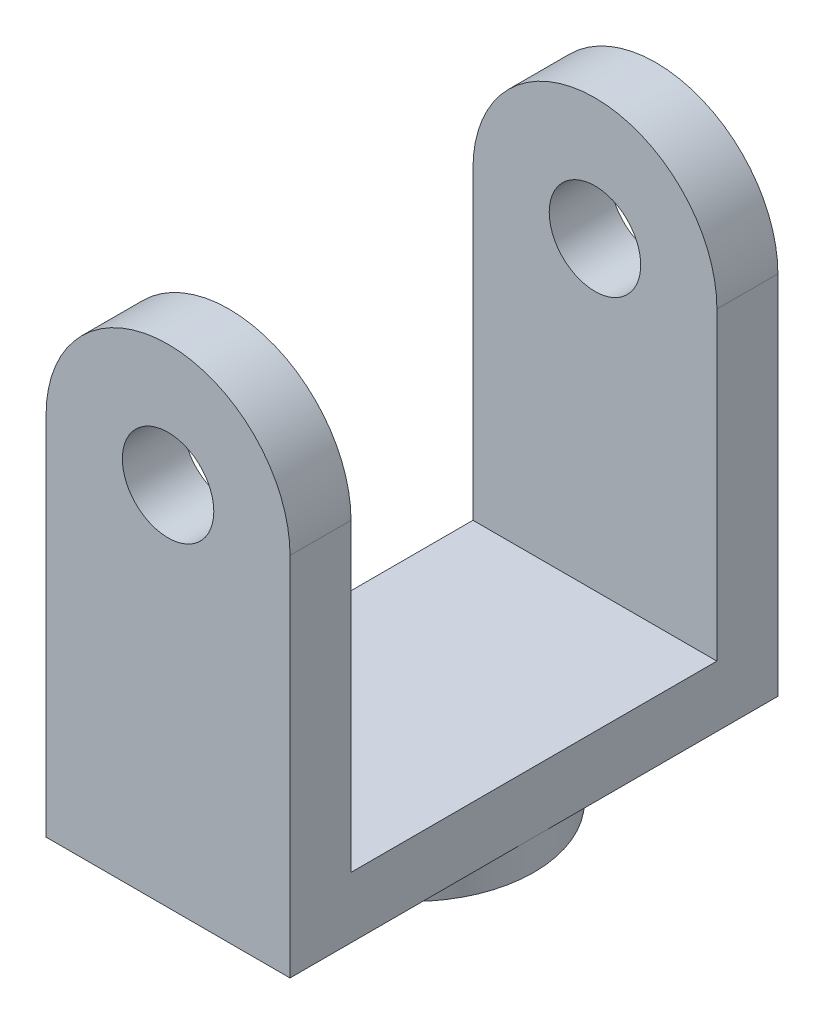
from build123d import *

# Parameters (mm, degrees)
SKETCH1_R               = 9.525
BOSS_EXTRUDE1_DEPTH     = 50.8
SKETCH2_W               = 76.2
SKETCH2_H               = 88.9
CUT_EXTRUDE1_DEPTH      = 26.4
CUT_EXTRUDE1_DEPTH_BACK = 26.4
SKETCH3_R               = 25.4
BOSS_EXTRUDE2_DEPTH     = 6.35


with BuildPart() as part:
    # Sketch1 → Boss-Extrude1 (new body, symmetric)
    with BuildSketch(Plane.XY):
        with BuildLine():
            Line((-25.4, 0), (-25.4, -76.2))
            Line((-25.4, -76.2), (25.4, -76.2))
            Line((25.4, -76.2), (25.4, 0))
            ThreePointArc((25.4, 0), (0, 25.4), (-25.4, 0))
        make_face()
        Circle(SKETCH1_R, mode=Mode.SUBTRACT)
    extrude(amount=BOSS_EXTRUDE1_DEPTH, both=True)

    # Sketch2 → Cut-Extrude1 (cut, two sides)
    with BuildSketch(Plane(origin=(0, 0, 0), x_dir=(0, 0, -1), z_dir=(1, 0, 0))) as cut_extrude1_sk:
        with Locations((0, -19.05)):
            Rectangle(SKETCH2_W, SKETCH2_H)
    extrude(amount=CUT_EXTRUDE1_DEPTH, mode=Mode.SUBTRACT)
    extrude(cut_extrude1_sk.sketch, amount=-CUT_EXTRUDE1_DEPTH_BACK, mode=Mode.SUBTRACT)

    # Sketch3 → Boss-Extrude2 (add)
    with BuildSketch(Plane.XZ.offset(76.2)):
        Circle(SKETCH3_R)
    extrude(amount=BOSS_EXTRUDE2_DEPTH)


solid = part.part
